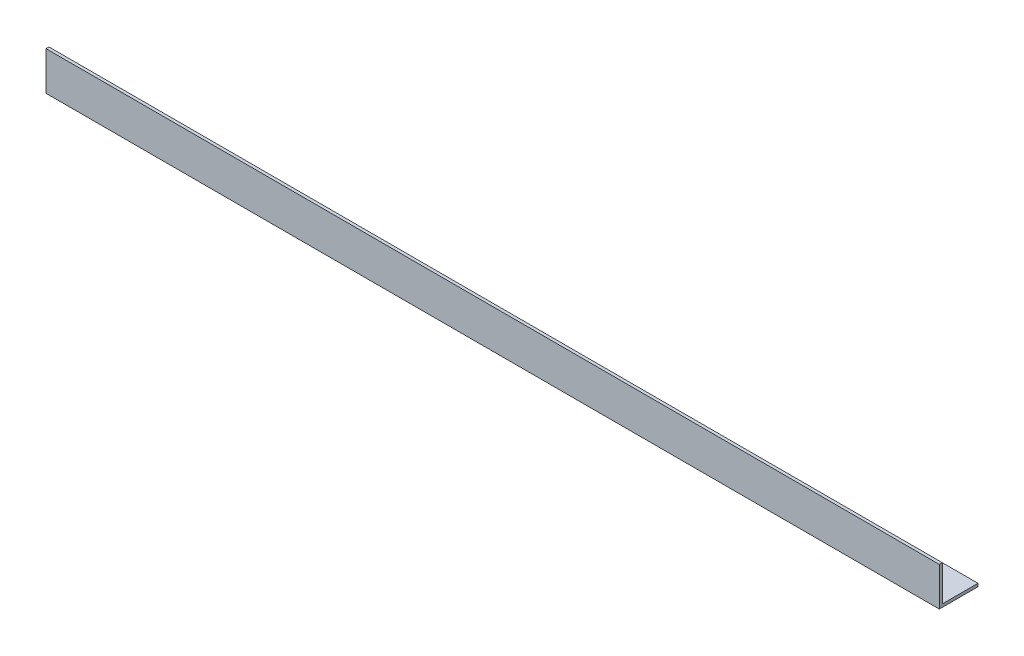
from build123d import *

# Parameters (mm, degrees)
EXTRUDE_1_DEPTH = 1500


with BuildPart() as part:
    # Эскиз1 → Вытянуть-Тонкостенный1 (new body)
    with BuildSketch(Plane(origin=(0, 0, 0), x_dir=(0, 0, -1), z_dir=(1, 0, 0))):
        Polygon((65, 0), (0, 0), (0, 65), (5, 65), (5, 5), (65, 5), align=None)
    extrude(amount=EXTRUDE_1_DEPTH)


solid = part.part
